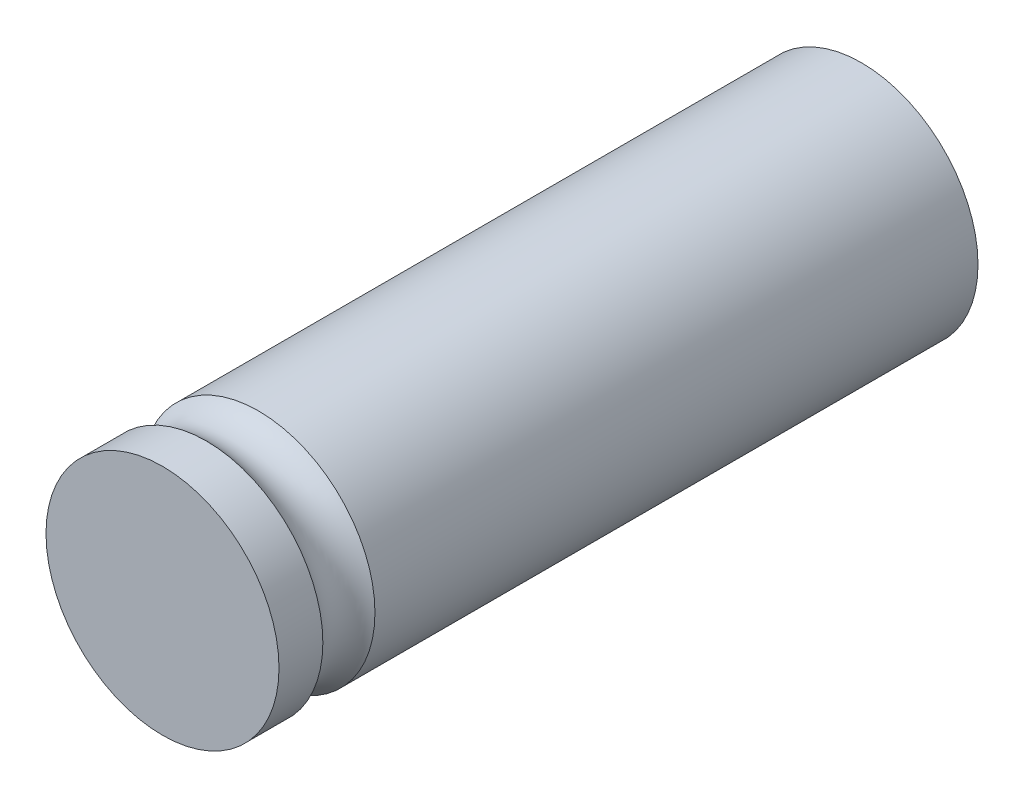
from build123d import *

# Parameters (mm, degrees)
ESQUISSE1_R        = 5
BOSS_EXTRU_1_DEPTH = 30
ESQUISSE2_R        = 1.5


with BuildPart() as part:
    # Esquisse1 → Boss.-Extru.1 (new body)
    with BuildSketch(Plane.XY):
        Circle(ESQUISSE1_R)
    extrude(amount=BOSS_EXTRU_1_DEPTH)

    # Esquisse2 → Enlèvement de matière-Révolution1 (revolve, cut)
    with BuildSketch(Plane(origin=(0, 0, 0), x_dir=(0, 0, -1), z_dir=(1, 0, 0))):
        with Locations((-27, 6)):
            Circle(ESQUISSE2_R)
    revolve(axis=Axis((0, 0, -1.5), (0, 0, 1)), mode=Mode.SUBTRACT)


solid = part.part
